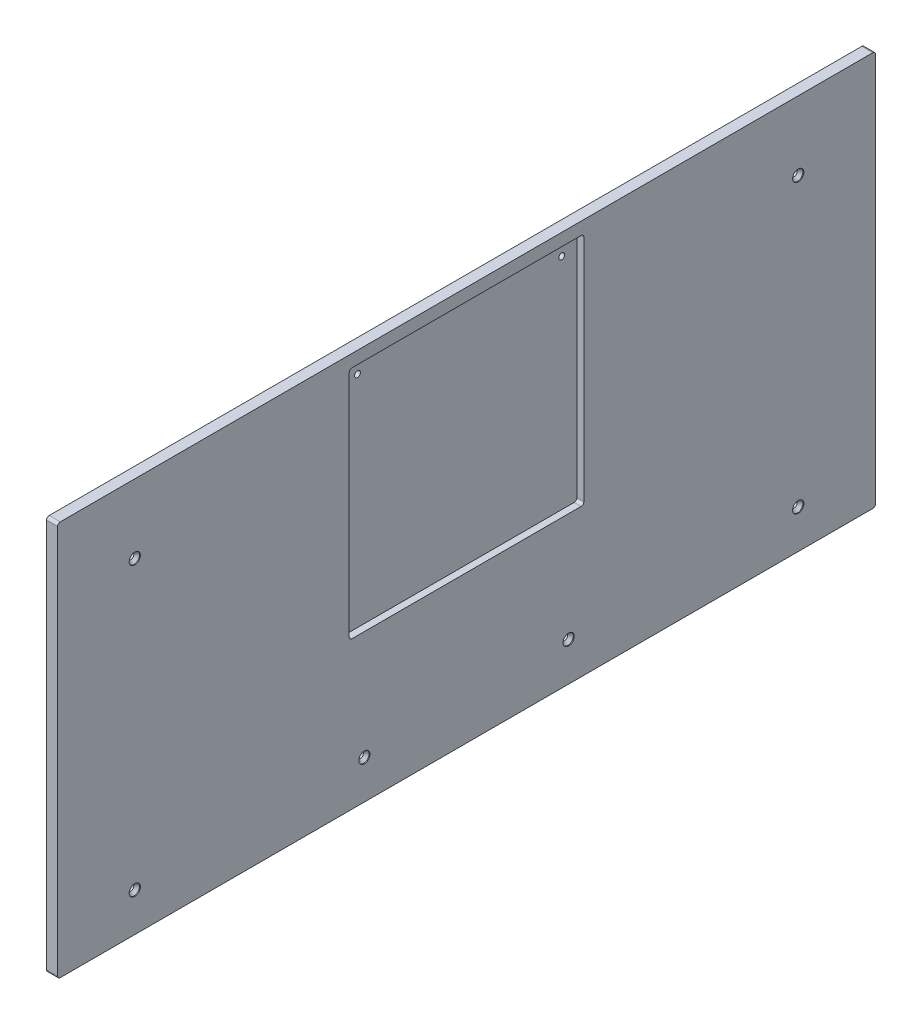
from build123d import *

# Parameters (mm, degrees)
SKETCH1_W                                     = 940.88204
SKETCH1_H                                     = 454.025
SKETCH1_R                                     = 3.3734375
BOSS_EXTRUDE1_DEPTH                           = 12.7
FILLET1_R                                     = 3.175
SKETCH2_W                                     = 269.875
SKETCH2_H                                     = 269.875
CUT_EXTRUDE1_DEPTH                            = 7.9375
FILLET2_R                                     = 3.175
CSK_FOR_1_4_FLAT_HEAD_MACHINE_SCREW1_AT_COUNT = 2
CSK_FOR_1_4_FLAT_HEAD_MACHINE_SCREW1_AT_PITCH = 763.08204
CSK_FOR_1_4_FLAT_HEAD_MACHINE_SCREW1_2_COUNT  = 2
CSK_FOR_1_4_FLAT_HEAD_MACHINE_SCREW1_2_PITCH  = 330.2
CSK_FOR_1_4_FLAT_HEAD_MACHINE_SCREW1_3_COUNT  = 2
CSK_FOR_1_4_FLAT_HEAD_MACHINE_SCREW1_3_PITCH  = 422.803622168
CSK_FOR_1_4_FLAT_HEAD_MACHINE_SCREW1_4_COUNT  = 2
CSK_FOR_1_4_FLAT_HEAD_MACHINE_SCREW1_4_PITCH  = 598.371981477
CSK_FOR_1_4_FLAT_HEAD_MACHINE_SCREW1_5_COUNT  = 2
CSK_FOR_1_4_FLAT_HEAD_MACHINE_SCREW1_5_PITCH  = 831.460305589


with BuildPart() as part:
    # Sketch1 → Boss-Extrude1 (new body)
    with BuildSketch(Plane(origin=(0, 0, 0), x_dir=(0, 0, -1), z_dir=(1, 0, 0))):
        with Locations((470.44102, 227.0125)):
            Rectangle(SKETCH1_W, SKETCH1_H)
        with Locations((352.96602, 422.275)):
            Circle(SKETCH1_R, mode=Mode.SUBTRACT)
        with Locations((587.91602, 422.275)):
            Circle(SKETCH1_R, mode=Mode.SUBTRACT)
    extrude(amount=BOSS_EXTRUDE1_DEPTH)

    # Fillet1
    fillet1_edges = [part.edges().sort_by_distance(p)[0] for p in [
        (6.35, 454.025, 0),
        (6.35, 454.025, -940.88204),
        (6.35, 0, -940.88204),
        (6.35, 0, 0),
    ]]
    fillet(fillet1_edges, radius=FILLET1_R)

    # Sketch2 → Cut-Extrude1 (cut)
    with BuildSketch(Plane(origin=(12.7, 0, 0), x_dir=(0, 0, -1), z_dir=(1, 0, 0))):
        with Locations((470.44102, 304.8)):
            Rectangle(SKETCH2_W, SKETCH2_H)
    extrude(amount=-CUT_EXTRUDE1_DEPTH, mode=Mode.SUBTRACT)

    # Fillet2
    fillet2_edges = [part.edges().sort_by_distance(p)[0] for p in [
        (8.73125, 169.8625, -335.50352),
        (8.73125, 439.7375, -335.50352),
        (8.73125, 439.7375, -605.37852),
        (8.73125, 169.8625, -605.37852),
    ]]
    fillet(fillet2_edges, radius=FILLET2_R)

    # Sketch5 → CSK for 1/4 Flat Head Machine Screw1 (revolve, cut)
    with BuildSketch(Plane(origin=(12.7, 374.65, -88.9), x_dir=(0, 0, -1), z_dir=(0, 1, 0))):
        Polygon((0, 0), (0, 12.7), (3.3782, 12.7), (3.3782, 4.536932584), (6.4389, 1.016), (6.4389, 0), align=None)
    csk_for_1_4_flat_head_machine_screw1 = revolve(axis=Axis((19.05, 374.65, -88.9), (-1, 0, 0)), mode=Mode.SUBTRACT)

    # CSK for 1/4 Flat Head Machine Screw1 at: CSK for 1/4 Flat Head Machine Screw1 ×2
    with Locations(*[(0, 0, -i * CSK_FOR_1_4_FLAT_HEAD_MACHINE_SCREW1_AT_PITCH) for i in range(1, CSK_FOR_1_4_FLAT_HEAD_MACHINE_SCREW1_AT_COUNT)]):
        add(csk_for_1_4_flat_head_machine_screw1, mode=Mode.SUBTRACT)

    # CSK for 1_4 Flat Head Machine Screw1 2: CSK for 1/4 Flat Head Machine Screw1 ×2
    with Locations(*[(0, -i * CSK_FOR_1_4_FLAT_HEAD_MACHINE_SCREW1_2_PITCH, 0) for i in range(1, CSK_FOR_1_4_FLAT_HEAD_MACHINE_SCREW1_2_COUNT)]):
        add(csk_for_1_4_flat_head_machine_screw1, mode=Mode.SUBTRACT)

    # CSK for 1_4 Flat Head Machine Screw1 3: CSK for 1/4 Flat Head Machine Screw1 ×2
    with Locations(*[Vector(0, -0.780977226, -0.624559503) * (i * CSK_FOR_1_4_FLAT_HEAD_MACHINE_SCREW1_3_PITCH) for i in range(1, CSK_FOR_1_4_FLAT_HEAD_MACHINE_SCREW1_3_COUNT)]):
        add(csk_for_1_4_flat_head_machine_screw1, mode=Mode.SUBTRACT)

    # CSK for 1_4 Flat Head Machine Screw1 4: CSK for 1/4 Flat Head Machine Screw1 ×2
    with Locations(*[Vector(0, -0.551830651, -0.833956194) * (i * CSK_FOR_1_4_FLAT_HEAD_MACHINE_SCREW1_4_PITCH) for i in range(1, CSK_FOR_1_4_FLAT_HEAD_MACHINE_SCREW1_4_COUNT)]):
        add(csk_for_1_4_flat_head_machine_screw1, mode=Mode.SUBTRACT)

    # CSK for 1_4 Flat Head Machine Screw1 5: CSK for 1/4 Flat Head Machine Screw1 ×2
    with Locations(*[Vector(0, -0.397132608, -0.917761239) * (i * CSK_FOR_1_4_FLAT_HEAD_MACHINE_SCREW1_5_PITCH) for i in range(1, CSK_FOR_1_4_FLAT_HEAD_MACHINE_SCREW1_5_COUNT)]):
        add(csk_for_1_4_flat_head_machine_screw1, mode=Mode.SUBTRACT)


solid = part.part
